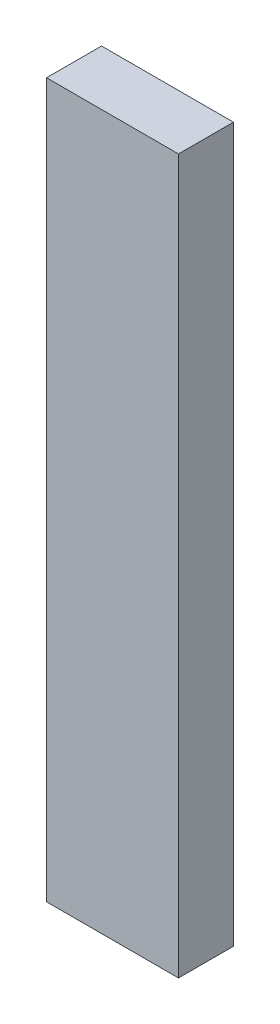
from build123d import *

# Parameters (mm, degrees)
SKETCH2_W           = 12
SKETCH2_H           = 5
BOSS_EXTRUDE1_DEPTH = 15
SKETCH3_W           = 12
SKETCH3_H           = 5
BOSS_EXTRUDE2_DEPTH = 57.00164
SKETCH4_W           = 12
SKETCH4_H           = 5
CUT_EXTRUDE1_DEPTH  = 7.1


with BuildPart() as part:
    # Sketch2 → Boss-Extrude1 (new body)
    with BuildSketch(Plane(origin=(0, 0, 0), x_dir=(1, 0, 0), z_dir=(0, 1, 0))):
        with Locations((-33.729716691, 72.811583722)):
            Rectangle(SKETCH2_W, SKETCH2_H)
    extrude(amount=BOSS_EXTRUDE1_DEPTH)

    # Sketch3 → Boss-Extrude2 (add)
    with BuildSketch(Plane.XZ):
        with Locations((-33.729716691, -72.811583722)):
            Rectangle(SKETCH3_W, SKETCH3_H)
    extrude(amount=BOSS_EXTRUDE2_DEPTH)

    # Sketch4 → Cut-Extrude1 (cut)
    with BuildSketch(Plane.XZ.offset(57.001640055)):
        with Locations((-33.729716691, -72.811583722)):
            Rectangle(SKETCH4_W, SKETCH4_H)
    extrude(amount=-CUT_EXTRUDE1_DEPTH, mode=Mode.SUBTRACT)


solid = part.part
